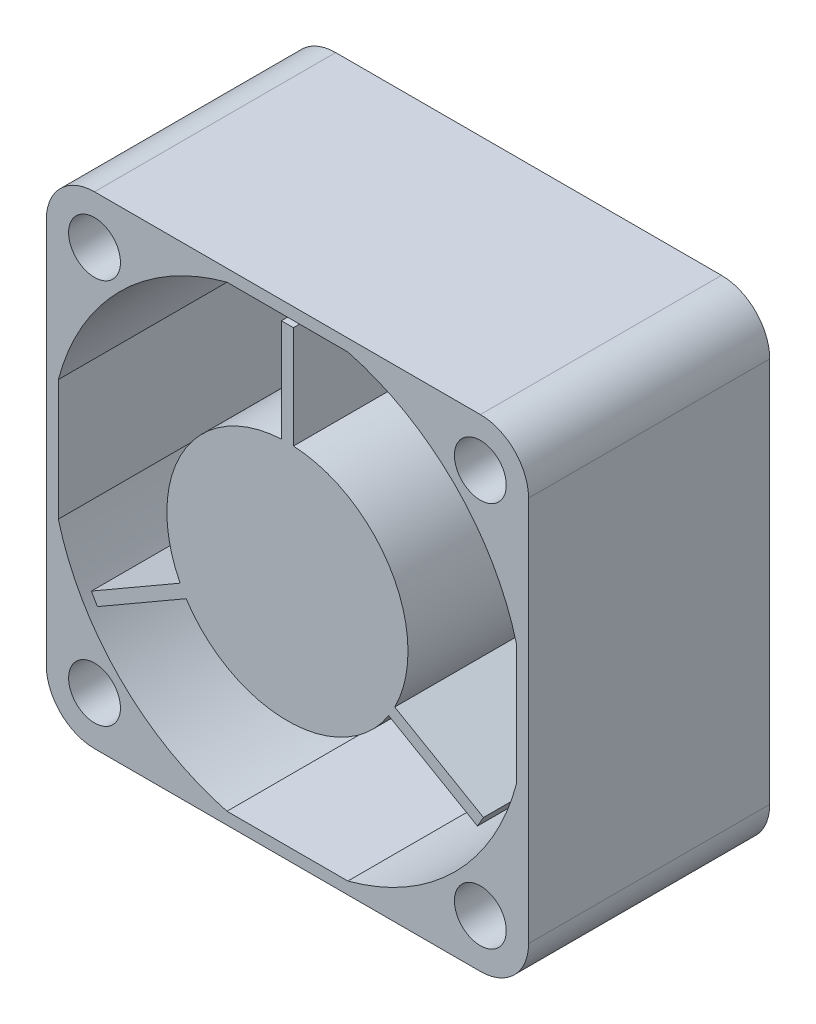
from build123d import *

# Parameters (mm, degrees)
SKETCH1_W                = 40
SKETCH1_H                = 40
SKETCH1_R                = 2.15
BOSS_EXTRUDE1_DEPTH      = 10
BOSS_EXTRUDE1_DEPTH_BACK = 10
FILLET1_R                = 4
BOSS_EXTRUDE2_DEPTH      = 20


with BuildPart() as part:
    # Sketch1 → Boss-Extrude1 (new body, two sides)
    with BuildSketch(Plane.XY) as boss_extrude1_sk:
        Rectangle(SKETCH1_W, SKETCH1_H)
        with Locations((-16, 16)):
            Circle(SKETCH1_R, mode=Mode.SUBTRACT)
        with Locations((16, 16)):
            Circle(SKETCH1_R, mode=Mode.SUBTRACT)
        with Locations((16, -16)):
            Circle(SKETCH1_R, mode=Mode.SUBTRACT)
        with Locations((-16, -16)):
            Circle(SKETCH1_R, mode=Mode.SUBTRACT)
        with BuildLine():
            Line((-5.01223503, 19), (5.01223503, 19))
            ThreePointArc((5.01223503, 19), (13.89464825, 13.89464825), (19, 5.01223503))
            Line((19, 5.01223503), (19, -5.01223503))
            ThreePointArc((19, -5.01223503), (13.89464825, -13.89464825), (5.01223503, -19))
            Line((5.01223503, -19), (-5.01223503, -19))
            ThreePointArc((-5.01223503, -19), (-13.89464825, -13.89464825), (-19, -5.01223503))
            Line((-19, -5.01223503), (-19, 5.01223503))
            ThreePointArc((-19, 5.01223503), (-13.89464825, 13.89464825), (-5.01223503, 19))
        make_face(mode=Mode.SUBTRACT)
    extrude(amount=BOSS_EXTRUDE1_DEPTH)
    extrude(boss_extrude1_sk.sketch, amount=-BOSS_EXTRUDE1_DEPTH_BACK)

    # Fillet1
    fillet1_edges = [part.edges().sort_by_distance(p)[0] for p in [
        (-20, 20, 0),
        (20, 20, 0),
        (20, -20, 0),
        (-20, -20, 0),
    ]]
    fillet(fillet1_edges, radius=FILLET1_R)


with BuildPart() as body_2:
    # Sketch2 → Boss-Extrude2 (new body)
    with BuildSketch(Plane.XY.offset(10)):
        with BuildLine():
            Line((-8.899421946, -4.560733387), (-16.260637878, -8.810733387))
            Line((-16.260637878, -8.810733387), (-15.760637878, -9.676758791))
            Line((-15.760637878, -9.676758791), (-8.399421946, -5.426758791))
            ThreePointArc((-8.399421946, -5.426758791), (0, -10), (8.399421946, -5.426758791))
            Line((8.399421946, -5.426758791), (15.760637878, -9.676758791))
            Line((15.760637878, -9.676758791), (16.260637878, -8.810733387))
            Line((16.260637878, -8.810733387), (8.899421946, -4.560733387))
            ThreePointArc((8.899421946, -4.560733387), (8.660254038, 5), (0.5, 9.987492178))
            Line((0.5, 9.987492178), (0.5, 18.487492178))
            Line((0.5, 18.487492178), (-0.5, 18.487492178))
            Line((-0.5, 18.487492178), (-0.5, 9.987492178))
            ThreePointArc((-0.5, 9.987492178), (-8.660254038, 5), (-8.899421946, -4.560733387))
        make_face()
    extrude(amount=-BOSS_EXTRUDE2_DEPTH)


solid = Compound([part.part, body_2.part])
